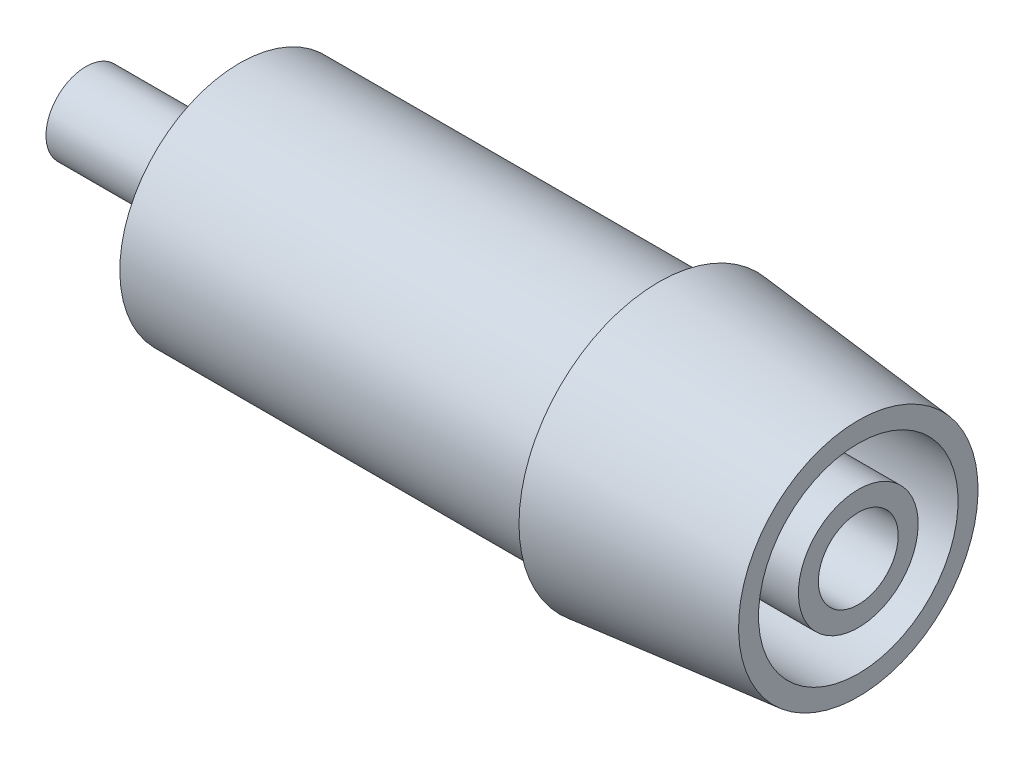
from build123d import *


with BuildPart() as part:
    # Szkic1 → Obrót1 (revolve)
    with BuildSketch(Plane.XY):
        Polygon((0, 0), (0, 2), (7.7, 2), (7.7, 6), (28.7, 6), (28.7, 7), (38.7, 6), (38.7, 5), (16.7, 5), (16.7, 3), (38.7, 3), (38.7, 2), (16.7, 2), (16.7, 0), align=None)
    revolve(axis=Axis((16.7, 0, 0), (-1, 0, 0)))


solid = part.part
